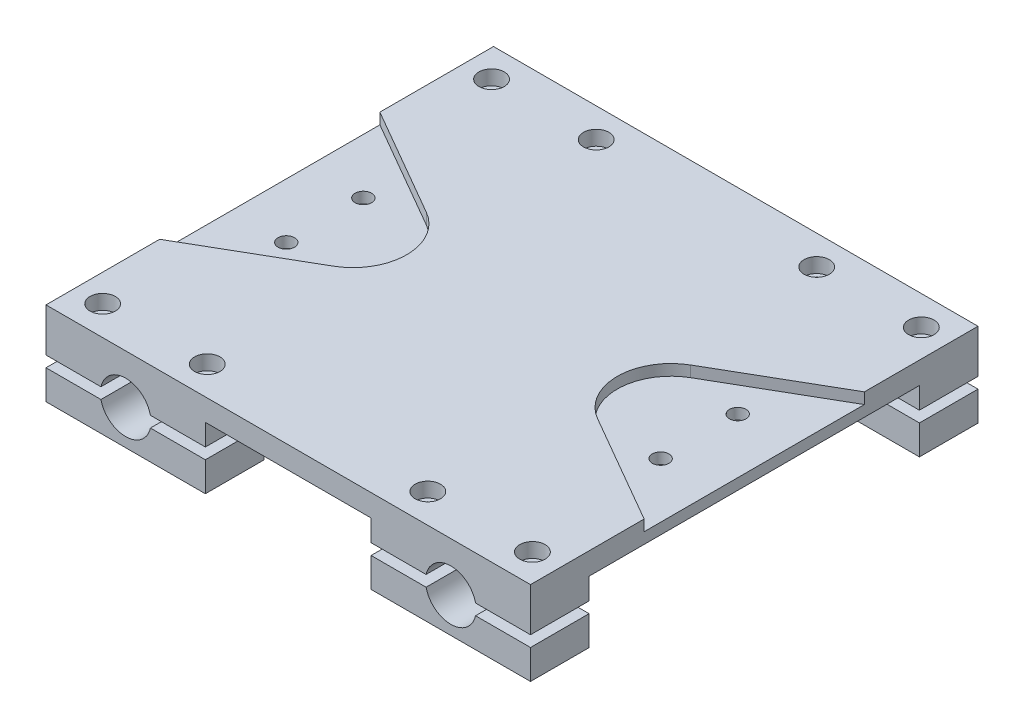
from build123d import *

# Parameters (mm, degrees)
SKETCH1_W           = 220
SKETCH1_H           = 31.75
SKETCH1_R           = 11.499999987
BOSS_EXTRUDE1_DEPTH = 203.2
SKETCH3_W           = 220
SKETCH3_H           = 6.35
BOSS_EXTRUDE2_DEPTH = 203.2
SKETCH4_W           = 150
SKETCH4_H           = 28.1
CUT_EXTRUDE1_DEPTH  = 253.2
SKETCH5_W           = 75.275
SKETCH5_H           = 28.1
CUT_EXTRUDE2_DEPTH  = 203.2
SKETCH6_R           = 3.7258
CUT_EXTRUDE3_DEPTH  = 203.2
SKETCH7_W           = 220
SKETCH7_H           = 5
CUT_EXTRUDE4_DEPTH  = 203.2
SKETCH8_W           = 150
SKETCH8_H           = 10
BOSS_EXTRUDE3_DEPTH = 132.41370821
SKETCH9_W           = 150
SKETCH9_H           = 10
BOSS_EXTRUDE4_DEPTH = 161.04729179
SKETCH10_R          = 3.7258
CUT_EXTRUDE5_DEPTH  = 10
SKETCH11_R          = 5.7625
CUT_EXTRUDE6_DEPTH  = 6.6675
SKETCH12_W          = 132.41370821
SKETCH12_H          = 150
SKETCH12_W_2        = 161.04729179
CUT_EXTRUDE8_DEPTH  = 82
SKETCH13_R          = 3.75
CUT_EXTRUDE10_DEPTH = 5
SKETCH16_R          = 3.75
CUT_EXTRUDE11_DEPTH = 5


with BuildPart() as part:
    # Sketch1 → Boss-Extrude1 (new body)
    with BuildSketch(Plane.XY):
        Rectangle(SKETCH1_W, SKETCH1_H)
        with Locations((-73.81875, 0)):
            Circle(SKETCH1_R, mode=Mode.SUBTRACT)
        with Locations((73.81875, 0)):
            Circle(SKETCH1_R, mode=Mode.SUBTRACT)
    extrude(amount=BOSS_EXTRUDE1_DEPTH)

    # Sketch3 → Boss-Extrude2 (add)
    with BuildSketch(Plane.XY.offset(203.2)):
        with Locations((0, 19.05)):
            Rectangle(SKETCH3_W, SKETCH3_H)
    extrude(amount=-BOSS_EXTRUDE2_DEPTH)

    # Sketch4 → Cut-Extrude1 (cut)
    with BuildSketch(Plane.ZY.offset(110)):
        with Locations((101.6, -1.825)):
            Rectangle(SKETCH4_W, SKETCH4_H)
    extrude(amount=-CUT_EXTRUDE1_DEPTH, mode=Mode.SUBTRACT)

    # Sketch5 → Cut-Extrude2 (cut)
    with BuildSketch(Plane(origin=(0, 0, 0), x_dir=(-1, 0, 0), z_dir=(0, 0, -1))):
        with Locations((0, -1.825)):
            Rectangle(SKETCH5_W, SKETCH5_H)
    extrude(amount=-CUT_EXTRUDE2_DEPTH, mode=Mode.SUBTRACT)

    # Sketch6 → Cut-Extrude3 (cut)
    with BuildSketch(Plane.XZ.offset(15.875)):
        with Locations((-50.06875, 189.9)):
            Circle(SKETCH6_R)
        with Locations((-97.56875, 189.9)):
            Circle(SKETCH6_R)
        with Locations((-97.56875, 13.3)):
            Circle(SKETCH6_R)
        with Locations((-50.06875, 13.3)):
            Circle(SKETCH6_R)
        with Locations((50.06875, 13.3)):
            Circle(SKETCH6_R)
        with Locations((97.56875, 13.3)):
            Circle(SKETCH6_R)
        with Locations((97.56875, 189.9)):
            Circle(SKETCH6_R)
        with Locations((50.06875, 189.9)):
            Circle(SKETCH6_R)
    extrude(amount=-CUT_EXTRUDE3_DEPTH, mode=Mode.SUBTRACT)

    # Sketch7 → Cut-Extrude4 (cut)
    with BuildSketch(Plane(origin=(0, 0, 0), x_dir=(-1, 0, 0), z_dir=(0, 0, -1))):
        Rectangle(SKETCH7_W, SKETCH7_H)
    extrude(amount=-CUT_EXTRUDE4_DEPTH, mode=Mode.SUBTRACT)

    # Sketch8 → Boss-Extrude3 (add)
    with BuildSketch(Plane.ZY.offset(110)):
        with Locations((101.6, 17.225)):
            Rectangle(SKETCH8_W, SKETCH8_H)
    extrude(amount=BOSS_EXTRUDE3_DEPTH)

    # Sketch9 → Boss-Extrude4 (add)
    with BuildSketch(Plane(origin=(110, 0, 0), x_dir=(0, 0, -1), z_dir=(1, 0, 0))):
        with Locations((-101.6, 17.225)):
            Rectangle(SKETCH9_W, SKETCH9_H)
    extrude(amount=BOSS_EXTRUDE4_DEPTH)

    # Sketch10 → Cut-Extrude5 (cut)
    with BuildSketch(Plane(origin=(0, 22.225, 0), x_dir=(1, 0, 0), z_dir=(0, 1, 0))):
        with Locations((-217.013708212, -152.4)):
            Circle(SKETCH10_R)
        with Locations((-217.013708212, -50.966658535)):
            Circle(SKETCH10_R)
        with Locations((245.647291788, -50.8)):
            Circle(SKETCH10_R)
        with Locations((245.647291788, -152.4)):
            Circle(SKETCH10_R)
    extrude(amount=-CUT_EXTRUDE5_DEPTH, mode=Mode.SUBTRACT)

    # Sketch11 → Cut-Extrude6 (cut)
    with BuildSketch(Plane(origin=(0, 22.225, 0), x_dir=(1, 0, 0), z_dir=(0, 1, 0))):
        with Locations((97.56875, -13.3)):
            Circle(SKETCH11_R)
        with Locations((50.06875, -13.3)):
            Circle(SKETCH11_R)
        with Locations((97.56875, -189.9)):
            Circle(SKETCH11_R)
        with Locations((50.06875, -189.9)):
            Circle(SKETCH11_R)
        with Locations((-50.06875, -189.9)):
            Circle(SKETCH11_R)
        with Locations((-97.56875, -189.9)):
            Circle(SKETCH11_R)
        with Locations((-97.56875, -13.3)):
            Circle(SKETCH11_R)
        with Locations((-50.06875, -13.3)):
            Circle(SKETCH11_R)
    extrude(amount=-CUT_EXTRUDE6_DEPTH, mode=Mode.SUBTRACT)

    # Sketch12 → Cut-Extrude8 (cut)
    with BuildSketch(Plane(origin=(0, 22.225, 0), x_dir=(1, 0, 0), z_dir=(0, 1, 0))):
        with Locations((-176.206854105, -101.6)):
            Rectangle(SKETCH12_W, SKETCH12_H)
        with Locations((190.523645895, -101.6)):
            Rectangle(SKETCH12_W_2, SKETCH12_H)
    extrude(amount=-CUT_EXTRUDE8_DEPTH, mode=Mode.SUBTRACT)

    # Sketch13 → Cut-Extrude10 (cut)
    with BuildSketch(Plane(origin=(0, 22.225, 0), x_dir=(1, 0, 0), z_dir=(0, 1, 0))):
        with BuildLine():
            ThreePointArc((60, -122.732486541), (47.799153207, -101.6), (60, -80.467513459))
            Line((60, -80.467513459), (110, -51.6))
            Line((110, -51.6), (110, -151.6))
            Line((110, -151.6), (60, -122.732486541))
        make_face()
        with Locations((85, -119.1)):
            Circle(SKETCH13_R, mode=Mode.SUBTRACT)
        with Locations((85, -84.1)):
            Circle(SKETCH13_R, mode=Mode.SUBTRACT)
        with BuildLine():
            Line((-60, -122.732486541), (-110, -151.6))
            Line((-110, -151.6), (-110, -51.6))
            Line((-110, -51.6), (-60, -80.467513459))
            ThreePointArc((-60, -80.467513459), (-47.799153207, -101.6), (-60, -122.732486541))
        make_face()
        with Locations((85, -119.1)):
            Circle(SKETCH13_R)
        with Locations((85, -84.1)):
            Circle(SKETCH13_R)
    extrude(amount=-CUT_EXTRUDE10_DEPTH, mode=Mode.SUBTRACT)

    # Sketch16 → Cut-Extrude11 (cut)
    with BuildSketch(Plane(origin=(0, 17.225, 0), x_dir=(1, 0, 0), z_dir=(0, 1, 0))):
        with Locations((-85, -84.1)):
            Circle(SKETCH16_R)
        with Locations((85, -119.1)):
            Circle(SKETCH16_R)
        with Locations((85, -84.1)):
            Circle(SKETCH16_R)
        with Locations((-85, -119.1)):
            Circle(SKETCH16_R)
    extrude(amount=-CUT_EXTRUDE11_DEPTH, mode=Mode.SUBTRACT)


solid = part.part
